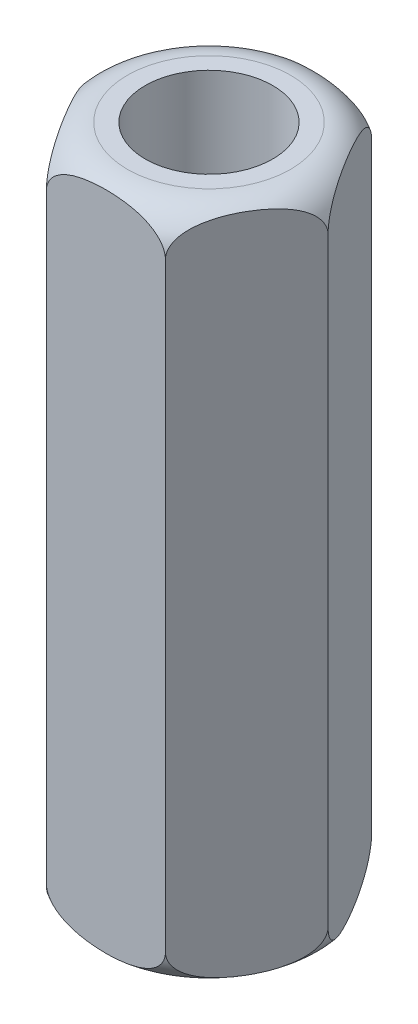
from build123d import *

# Parameters (mm, degrees)
BOSS_EXTRUDE1_DEPTH      = 18
M3_CLEARANCE_HOLE1_D     = 3.4
M3_CLEARANCE_HOLE1_DEPTH = 20
M3_CLEARANCE_HOLE1_TIP   = 1.021463052


with BuildPart() as part:
    # Sketch1 → Boss-Extrude1 (new body)
    with BuildSketch(Plane(origin=(0, 0, 0), x_dir=(1, 0, 0), z_dir=(0, 1, 0))):
        Polygon((3.175426481, 0), (1.58771324, 2.75), (-1.58771324, 2.75), (-3.175426481, 0), (-1.58771324, -2.75), (1.58771324, -2.75), align=None)
    extrude(amount=BOSS_EXTRUDE1_DEPTH)

    # M3 Clearance Hole1
    with Locations(Plane(origin=(0, 18, 0), x_dir=(-1, 0, 0), z_dir=(0, 1, 0))):
        with Locations((0, 0)):
            Hole(M3_CLEARANCE_HOLE1_D / 2, depth=M3_CLEARANCE_HOLE1_DEPTH)
            with Locations((0, 0, -(M3_CLEARANCE_HOLE1_DEPTH + M3_CLEARANCE_HOLE1_TIP / 2))):  # 118° drill point
                Cone(0, M3_CLEARANCE_HOLE1_D / 2, M3_CLEARANCE_HOLE1_TIP, mode=Mode.SUBTRACT)

    # Sketch4 → Cut-Revolve1 (revolve, cut)
    with BuildSketch(Plane.XY):
        with BuildLine():
            Line((-2.175426481, 18), (-3.175426481, 18))
            Line((-3.175426481, 18), (-3.175426481, 17))
            ThreePointArc((-3.175426481, 17), (-2.882533262, 17.707106781), (-2.175426481, 18))
        make_face()
        with BuildLine():
            Line((-3.175426481, 1), (-3.175426481, 0))
            Line((-3.175426481, 0), (-2.175426481, 0))
            ThreePointArc((-2.175426481, 0), (-2.882533262, 0.292893219), (-3.175426481, 1))
        make_face()
    revolve(axis=Axis((0, 18, 0), (0, -1, 0)), mode=Mode.SUBTRACT)


solid = part.part
